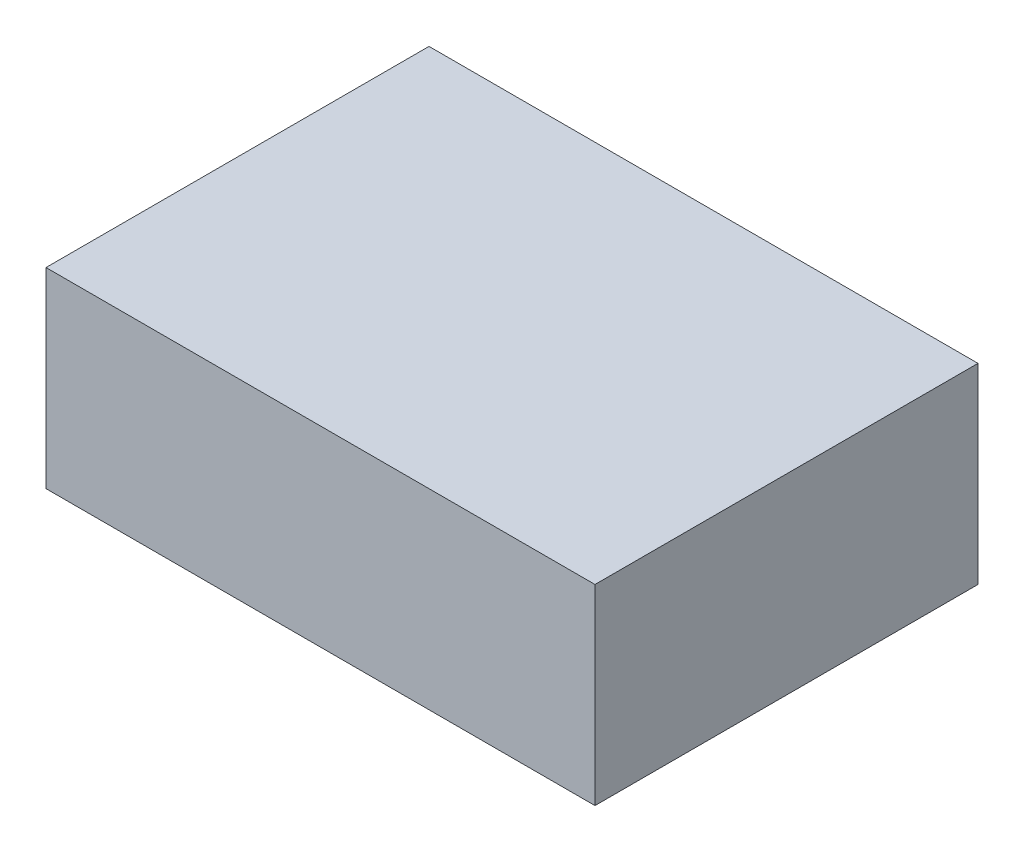
from build123d import *

# Parameters (mm, degrees)
SKETCH1_W           = 43
SKETCH1_H           = 30
BOSS_EXTRUDE1_DEPTH = 15


with BuildPart() as part:
    # Sketch1 → Boss-Extrude1 (new body)
    with BuildSketch(Plane(origin=(0, 0, 0), x_dir=(1, 0, 0), z_dir=(0, 1, 0))):
        with Locations((21.5, 15)):
            Rectangle(SKETCH1_W, SKETCH1_H)
    extrude(amount=BOSS_EXTRUDE1_DEPTH)


solid = part.part
